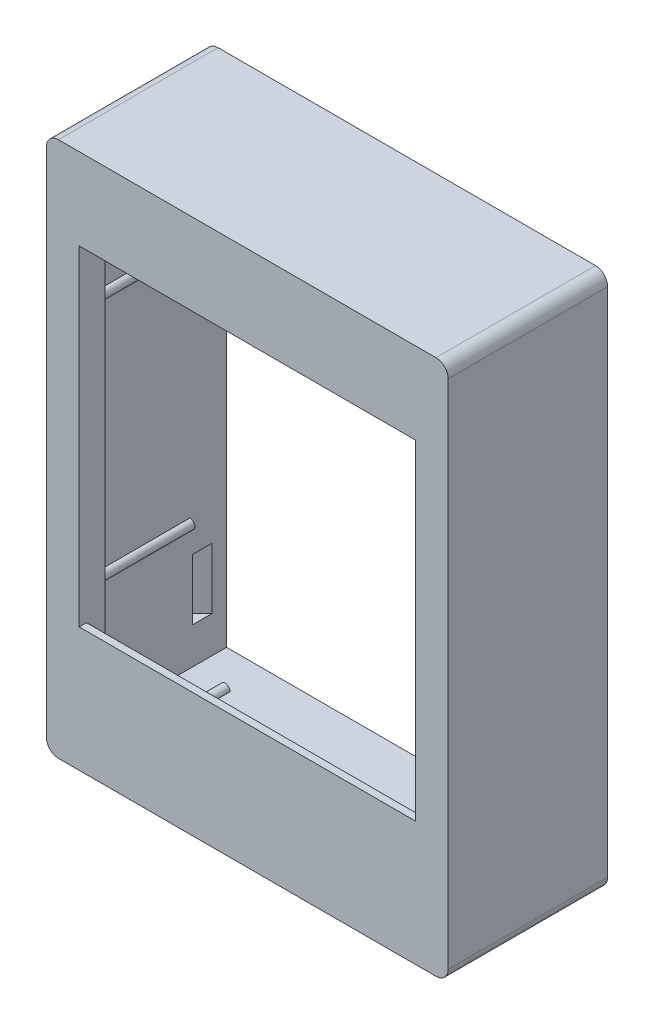
from build123d import *

# Parameters (mm, degrees)
SKETCH_1_W          = 33
SKETCH_1_H          = 44
EXTRUDE_1_DEPTH     = 12.5
SKETCH_2_W          = 29.6
SKETCH_2_H          = 40.6
CUT_EXTRUDE_2_DEPTH = 11
SKETCH_3_W          = 27.6
SKETCH_3_H          = 31.1
CUT_EXTRUDE_3_DEPTH = 2.5
SKETCH_4_W          = 18
SKETCH_4_H          = 3
CUT_EXTRUDE_4_DEPTH = 0.7
FILLET_1_R          = 1
SKETCH_5_W          = 27.6
SKETCH_5_H          = 0.6
EXTRUDE_2_DEPTH     = 1
EXTRUDE_3_DEPTH     = 8
EXTRUDE_4_DEPTH     = 0.6
SKETCH_8_W          = 27.6
SKETCH_8_H          = 27.1
CUT_EXTRUDE_5_DEPTH = 1.6
CUT_EXTRUDE_6_DEPTH = 5


with BuildPart() as part:
    # 草图1 → 凸台-拉伸1 (new body)
    with BuildSketch(Plane.XY):
        with Locations((16.5, 22)):
            Rectangle(SKETCH_1_W, SKETCH_1_H)
    extrude(amount=EXTRUDE_1_DEPTH)

    # 草图2 → 切除-拉伸2 (cut)
    with BuildSketch(Plane(origin=(0, 0, 0), x_dir=(-1, 0, 0), z_dir=(0, 0, -1))):
        with Locations((-16.5, 22)):
            Rectangle(SKETCH_2_W, SKETCH_2_H)
    extrude(amount=-CUT_EXTRUDE_2_DEPTH, mode=Mode.SUBTRACT)

    # 草图3 → 切除-拉伸3 (cut, through all)
    with BuildSketch(Plane(origin=(0, 0, 11), x_dir=(-1, 0, 0), z_dir=(0, 0, -1))):
        with Locations((-16.5, 21.75)):
            Rectangle(SKETCH_3_W, SKETCH_3_H)
    extrude(amount=-CUT_EXTRUDE_3_DEPTH, mode=Mode.SUBTRACT)

    # 草图4 → 切除-拉伸4 (cut)
    with BuildSketch(Plane(origin=(0, 0, 11), x_dir=(-1, 0, 0), z_dir=(0, 0, -1))):
        with Locations((-16.5, 40.8)):
            Rectangle(SKETCH_4_W, SKETCH_4_H)
    extrude(amount=-CUT_EXTRUDE_4_DEPTH, mode=Mode.SUBTRACT)

    # 圆角1
    fillet_1_edges = [part.edges().sort_by_distance(p)[0] for p in [
        (0, 44, 6.25),
        (33, 44, 6.25),
        (33, 0, 6.25),
        (0, 0, 6.25),
    ]]
    fillet(fillet_1_edges, radius=FILLET_1_R)

    # 草图5 → 凸台-拉伸2 (add)
    with BuildSketch(Plane(origin=(0, 6.2, 0), x_dir=(1, 0, 0), z_dir=(0, 1, 0))):
        with Locations((16.5, -12.2)):
            Rectangle(SKETCH_5_W, SKETCH_5_H)
    extrude(amount=EXTRUDE_2_DEPTH)

    # 草图6 → 凸台-拉伸3 (add)
    with BuildSketch(Plane(origin=(0, 0, 11), x_dir=(-1, 0, 0), z_dir=(0, 0, -1))):
        with BuildLine():
            Line((-31.3, 11.6), (-31.3, 12.4))
            ThreePointArc((-31.3, 12.4), (-30.9, 12), (-31.3, 11.6))
        make_face()
        with BuildLine():
            Line((-31.3, 32.4), (-31.3, 31.6))
            ThreePointArc((-31.3, 31.6), (-30.9, 32), (-31.3, 32.4))
        make_face()
        with BuildLine():
            Line((-28.8, 42.3), (-28, 42.3))
            ThreePointArc((-28, 42.3), (-28.4, 41.9), (-28.8, 42.3))
        make_face()
        with BuildLine():
            Line((-28.8, 1.7), (-28, 1.7))
            ThreePointArc((-28, 1.7), (-28.4, 2.1), (-28.8, 1.7))
        make_face()
        with BuildLine():
            Line((-4.2, 1.7), (-5, 1.7))
            ThreePointArc((-5, 1.7), (-4.6, 2.1), (-4.2, 1.7))
        make_face()
        with BuildLine():
            Line((-4.2, 42.3), (-5, 42.3))
            ThreePointArc((-5, 42.3), (-4.6, 41.9), (-4.2, 42.3))
        make_face()
        with BuildLine():
            Line((-1.7, 32.4), (-1.7, 31.6))
            ThreePointArc((-1.7, 31.6), (-2.1, 32), (-1.7, 32.4))
        make_face()
        with BuildLine():
            Line((-1.7, 11.6), (-1.7, 12.4))
            ThreePointArc((-1.7, 12.4), (-2.1, 12), (-1.7, 11.6))
        make_face()
    extrude(amount=EXTRUDE_3_DEPTH)

    # 草图7 → 凸台-拉伸4 (add)
    with BuildSketch(Plane.XY.offset(12.5)):
        with BuildLine():
            Line((0, 43), (0, 1))
            ThreePointArc((0, 1), (0.292893219, 0.292893219), (1, 0))
            Line((1, 0), (32, 0))
            ThreePointArc((32, 0), (32.707106781, 0.292893219), (33, 1))
            Line((33, 1), (33, 43))
            ThreePointArc((33, 43), (32.707106781, 43.707106781), (32, 44))
            Line((32, 44), (1, 44))
            ThreePointArc((1, 44), (0.292893219, 43.707106781), (0, 43))
        make_face()
    extrude(amount=EXTRUDE_4_DEPTH)

    # 草图8 → 切除-拉伸5 (cut, through all)
    with BuildSketch(Plane(origin=(0, 0, 12.5), x_dir=(-1, 0, 0), z_dir=(0, 0, -1))):
        with Locations((-16.5, 23.75)):
            Rectangle(SKETCH_8_W, SKETCH_8_H)
    extrude(amount=-CUT_EXTRUDE_5_DEPTH, mode=Mode.SUBTRACT)

    # 草图9 → 切除-拉伸6 (cut)
    with BuildSketch(Plane(origin=(0, 34.3, 0), x_dir=(-1, 0, 0), z_dir=(0, -1, 0))):
        Polygon((-31.3, -1.2), (-32.1, -2), (-31.3, -2.8), align=None)
        Polygon((-1.7, -2.8), (-1.7, -1.2), (-0.9, -2), align=None)
    cut_extrude_6 = extrude(amount=-CUT_EXTRUDE_6_DEPTH, mode=Mode.SUBTRACT)

    # 镜向1: 切除-拉伸6 across plane
    add(cut_extrude_6.mirror(Plane(origin=(0, 22, 0), x_dir=(0, 0, 1), z_dir=(0, -1, 0))), mode=Mode.SUBTRACT)


solid = part.part
